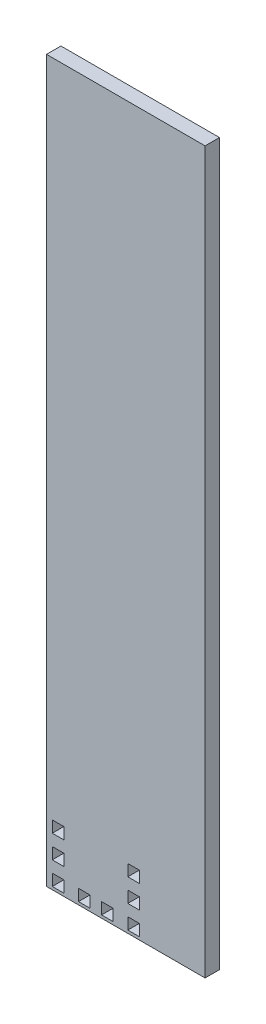
from build123d import *

# Parameters (mm, degrees)
ESQUISSE1_W        = 55
ESQUISSE1_H        = 250
ESQUISSE1_W_2      = 4
ESQUISSE1_H_2      = 4
BOSS_EXTRU_1_DEPTH = 5


with BuildPart() as part:
    # Esquisse1 → Boss.-Extru.1 (new body)
    with BuildSketch(Plane.XY):
        with Locations((27.5, 125)):
            Rectangle(ESQUISSE1_W, ESQUISSE1_H)
        with Locations((30.2, 19)):
            Rectangle(ESQUISSE1_W_2, ESQUISSE1_H_2, mode=Mode.SUBTRACT)
        with Locations((30.2, 11)):
            Rectangle(ESQUISSE1_W_2, ESQUISSE1_H_2, mode=Mode.SUBTRACT)
        with Locations((30.2, 3)):
            Rectangle(ESQUISSE1_W_2, ESQUISSE1_H_2, mode=Mode.SUBTRACT)
        with Locations((21.1, 3)):
            Rectangle(ESQUISSE1_W_2, ESQUISSE1_H_2, mode=Mode.SUBTRACT)
        with Locations((13.1, 3)):
            Rectangle(ESQUISSE1_W_2, ESQUISSE1_H_2, mode=Mode.SUBTRACT)
        with Locations((4, 3)):
            Rectangle(ESQUISSE1_W_2, ESQUISSE1_H_2, mode=Mode.SUBTRACT)
        with Locations((4, 11)):
            Rectangle(ESQUISSE1_W_2, ESQUISSE1_H_2, mode=Mode.SUBTRACT)
        with Locations((4, 19)):
            Rectangle(ESQUISSE1_W_2, ESQUISSE1_H_2, mode=Mode.SUBTRACT)
    extrude(amount=BOSS_EXTRU_1_DEPTH)


solid = part.part
